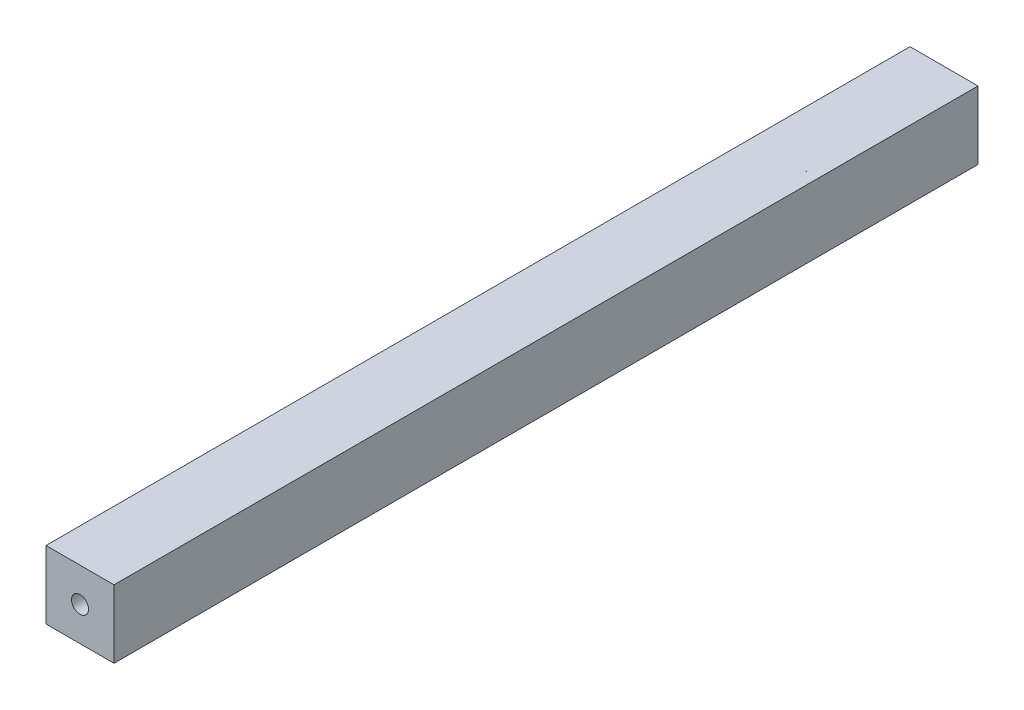
from build123d import *

# Parameters (mm, degrees)
SKETCH1_W           = 20
SKETCH1_H           = 20
BOSS_EXTRUDE1_DEPTH = 254
SKETCH2_R           = 2.5
CUT_EXTRUDE1_DEPTH  = 254


with BuildPart() as part:
    # Sketch1 → Boss-Extrude1 (new body)
    with BuildSketch(Plane.XY):
        Rectangle(SKETCH1_W, SKETCH1_H)
    extrude(amount=BOSS_EXTRUDE1_DEPTH)

    # Sketch2 → Cut-Extrude1 (cut)
    with BuildSketch(Plane.XY.offset(254)):
        Circle(SKETCH2_R)
    extrude(amount=-CUT_EXTRUDE1_DEPTH, mode=Mode.SUBTRACT)


solid = part.part
